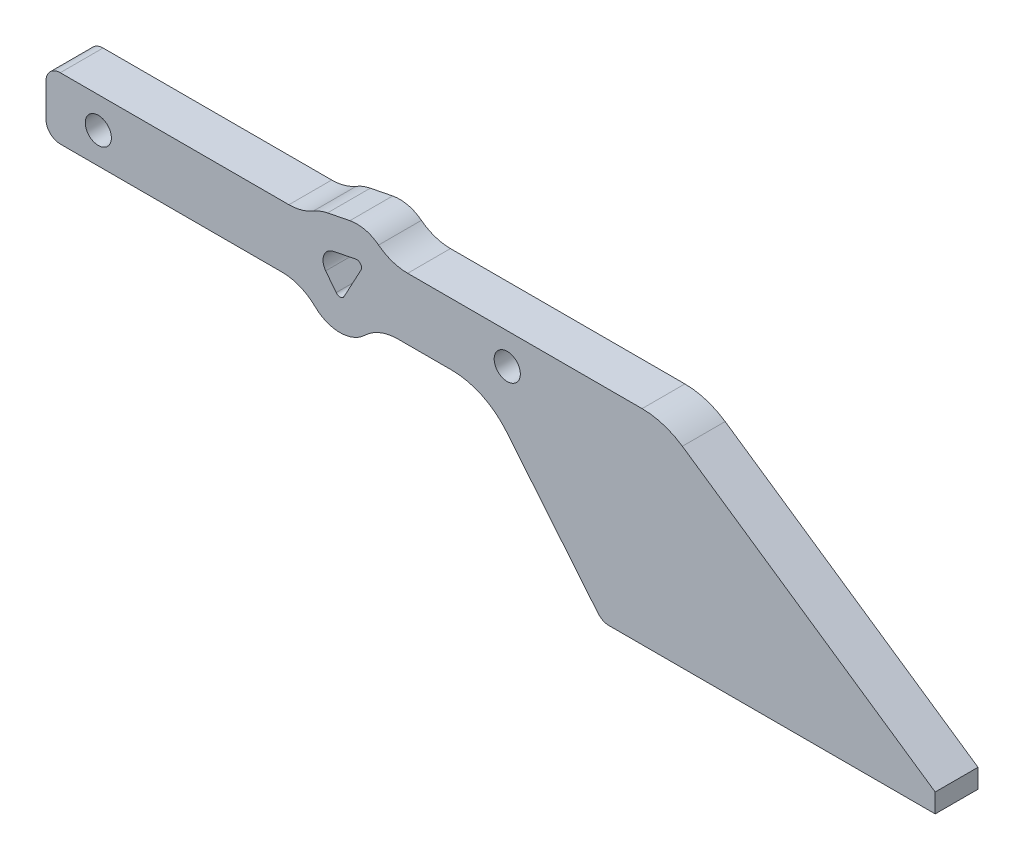
from build123d import *

# Parameters (mm, degrees)
SKETCH3_R           = 2.75
BOSS_EXTRUDE3_DEPTH = 4.5
FILLET13_R          = 15
FILLET14_R          = 10
FILLET15_R          = 3


with BuildPart() as part:
    # Sketch3 → Boss-Extrude3 (new body, symmetric)
    with BuildSketch(Plane.XY):
        with BuildLine():
            Line((-70, 0), (0, 0))
            Line((0, 0), (0, 4))
            Line((0, 4), (-57, 43))
            Line((-57, 43), (-115.201993943, 43))
            ThreePointArc((-115.201993943, 43), (-118.592897096, 46.002238478), (-123.093883581, 46.505011528))
            Line((-123.093883581, 46.505011528), (-127.796667749, 45.573835187))
            ThreePointArc((-127.796667749, 45.573835187), (-130.382170861, 44.646108184), (-132.581223291, 43))
            Line((-132.581223291, 43), (-187, 43))
            Line((-187, 43), (-187, 30))
            Line((-187, 30), (-132.669349371, 30))
            Line((-132.669349371, 30), (-131.12697347, 27.997184072))
            ThreePointArc((-131.12697347, 27.997184072), (-124.580147263, 25.097686291), (-118.584421639, 29.011673389))
            Line((-118.584421639, 29.011673389), (-118.051115414, 30))
            Line((-118.051115414, 30), (-94.638255551, 30))
            Line((-94.638255551, 30), (-70, 0))
        make_face()
        with Locations((-90, 36.5)):
            Circle(SKETCH3_R, mode=Mode.SUBTRACT)
        with BuildLine():
            ThreePointArc((-128.178796519, 34.822100799), (-128.574163723, 37.467564533), (-126.534144466, 39.197626677))
            Line((-126.534144466, 39.197626677), (-121.831360298, 40.128803018))
            ThreePointArc((-121.831360298, 40.128803018), (-120.832483215, 39.741607136), (-120.757075346, 38.672967941))
            Line((-120.757075346, 38.672967941), (-124.304750544, 32.09839288))
            ThreePointArc((-124.304750544, 32.09839288), (-125.104180628, 31.576527934), (-125.977090788, 31.963127638))
            Line((-125.977090788, 31.963127638), (-128.178796519, 34.822100799))
        make_face(mode=Mode.SUBTRACT)
        with Locations((-176, 36.5)):
            Circle(SKETCH3_R, mode=Mode.SUBTRACT)
    extrude(amount=BOSS_EXTRUDE3_DEPTH, both=True)

    # Fillet13
    fillet13_edges = [part.edges().sort_by_distance(p)[0] for p in [
        (-57, 43, 0),
        (-94.638255551, 30, 0),
    ]]
    fillet(fillet13_edges, radius=FILLET13_R)

    # Fillet14
    fillet14_edges = [part.edges().sort_by_distance(p)[0] for p in [
        (-115.201993943, 43, 0),
        (-132.581223291, 43, 0),
        (-132.669349371, 30, 0),
        (-118.051115414, 30, 0),
    ]]
    fillet(fillet14_edges, radius=FILLET14_R)

    # Fillet15
    fillet15_edges = [part.edges().sort_by_distance(p)[0] for p in [
        (-70, 0, 0),
        (-187, 30, 0),
        (-187, 43, 0),
    ]]
    fillet(fillet15_edges, radius=FILLET15_R)


solid = part.part
